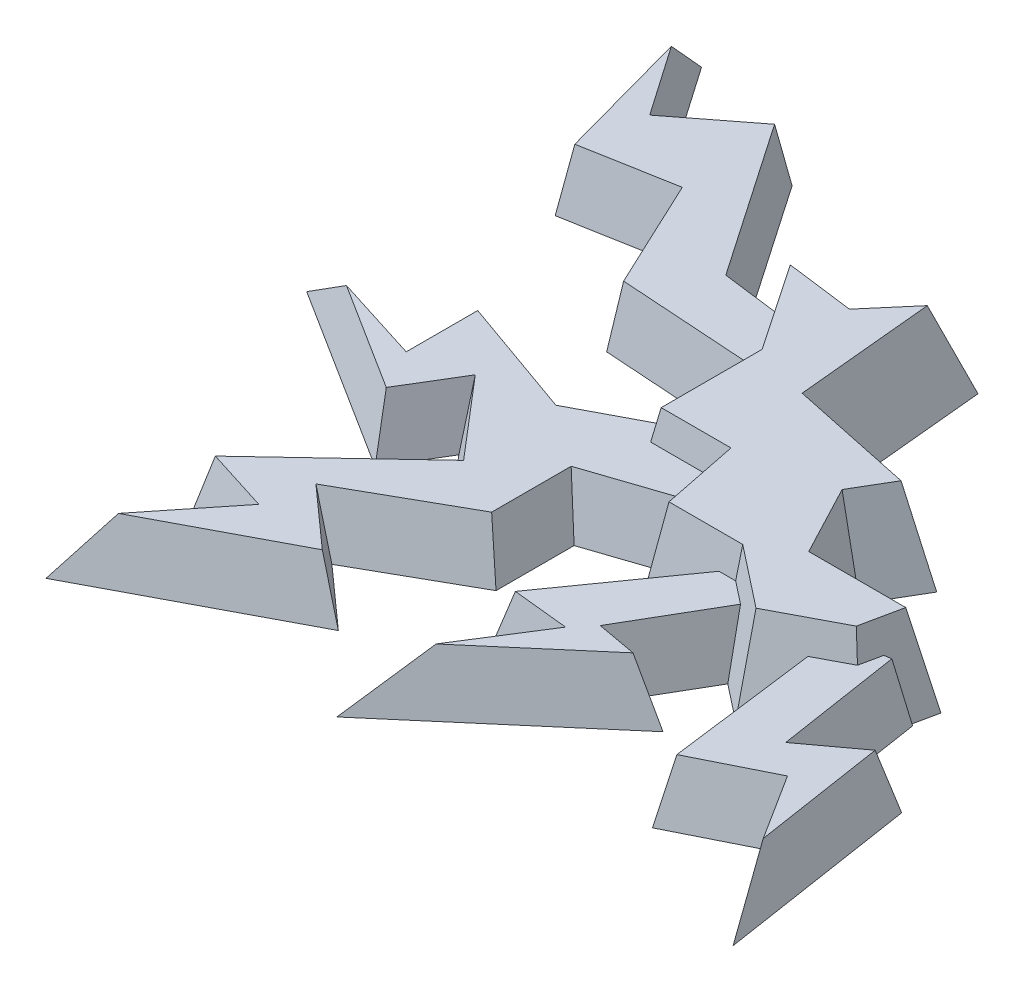
from build123d import *

# Parameters (mm, degrees)
BOSS_EXTRUDE1_DEPTH = 3
BOSS_EXTRUDE1_TAPER = 10
BOSS_EXTRUDE2_DEPTH = 2
BOSS_EXTRUDE2_TAPER = 10


with BuildPart() as part:
    # Sketch2 → Boss-Extrude1 (new body)
    with BuildSketch(Plane(origin=(0, 0, 0), x_dir=(1, 0, 0), z_dir=(0, 1, 0))):
        Polygon((-1.528324253, 5.492415284), (-3.355149336, 3.355149336), (-6.507318108, 3.761110466), (-3.964091031, 0), (-3.964091031, -3.748296105), (-1.528324253, -3.748296105), (-1.002962791, -6.352097676), (1.719364784, -6.352097676), (3.916975027, -8.077462319), (6.642811529, -6.642811529), (7.116259803, -4.393932227), (3.534249835, -4.393932227), (2.579047177, -2.579047177), (3.534249835, -0.955202658), (-1.002962791, 0), align=None)
    extrude(amount=BOSS_EXTRUDE1_DEPTH, taper=BOSS_EXTRUDE1_TAPER)

    # Sketch3 → Boss-Extrude2 (add)
    with BuildSketch(Plane(origin=(0, 0, 0), x_dir=(1, 0, 0), z_dir=(0, 1, 0))):
        Polygon((10.386967226, -14.630930723), (9.354403277, -7.948617551), (7.630259288, -9.221195787), (7.015272692, -5.241265011), (4.708870367, -5.597654757), (5.613726928, -12.562233064), (8.245836253, -11.251331436), align=None)
        Polygon((3.707378368, -5.391000258), (1.988983683, -4.390600081), (-2.180835877, -10.285076618), (-0.270036733, -10.483558335), (-2.891449297, -14.630930723), (3.003431491, -9.596279278), (1.427179104, -9.307715176), align=None)
        Polygon((-11.789266005, -15.483155877), (-5.37466541, -12.099434913), (-7.404660906, -10.285076618), (-3.889999551, -8.299445569), (-3.889999551, -5.68241554), (1.090991617, -4.01155513), (-0.815187592, -0.637527311), (-6.297024016, -3.52921239), (-10.680628975, -1.975898906), (-10.680628975, -4.390600081), (-15.742910277, -2.79186121), (-9.511821995, -6.730319487), (-8.455251073, -4.981182544), (-6.701594742, -7.03447166), (-11.179985311, -11.251331436), (-8.967737144, -11.949990188), align=None)
        Polygon((-15.639992384, 10.338429497), (-13.782364953, 3.575498575), (-10.680628975, 4.134580902), (-8.967737144, 0.485871688), (-1.660461726, 0), (-3.965321164, 2.653546974), (-6.995301565, 3.038510834), (-10.680628975, 8.413901489), (-13.040069267, 6.586416727), align=None)
    extrude(amount=BOSS_EXTRUDE2_DEPTH, taper=BOSS_EXTRUDE2_TAPER)


solid = part.part
